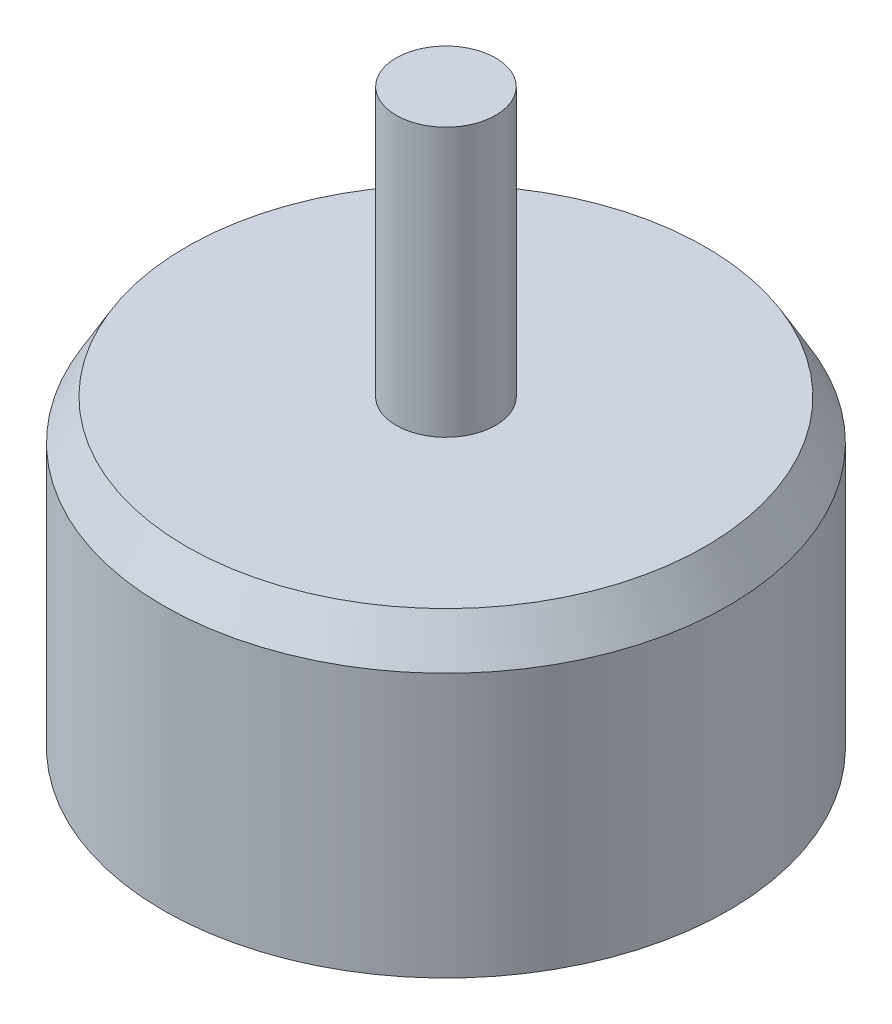
from build123d import *

# Parameters (mm, degrees)
SKETCH1_R                    = 14.2
BOSS_EXTRUDE1_DEPTH          = 17
SKETCH2_R                    = 2.5
BOSS_EXTRUDE2_DEPTH          = 13.5
CHAMFER1_SIZE                = 2
CHAMFER1_SIZE2               = 1.154700538
F_3_0_3_DIAMETER_HOLE1_D     = 3
F_3_0_3_DIAMETER_HOLE1_DEPTH = 5
F_3_0_3_DIAMETER_HOLE1_TIP   = 0.901290929
CHAMFER3_SIZE                = 3
CHAMFER3_SIZE2               = 1.732050808
SKETCH6_R                    = 5
BOSS_EXTRUDE3_DEPTH          = 2


with BuildPart() as part:
    # Sketch1 → Boss-Extrude1 (new body)
    with BuildSketch(Plane(origin=(0, 0, 0), x_dir=(1, 0, 0), z_dir=(0, 1, 0))):
        Circle(SKETCH1_R)
    extrude(amount=BOSS_EXTRUDE1_DEPTH)

    # Sketch2 → Boss-Extrude2 (add)
    with BuildSketch(Plane(origin=(0, 17, 0), x_dir=(1, 0, 0), z_dir=(0, 1, 0))):
        Circle(SKETCH2_R)
    extrude(amount=BOSS_EXTRUDE2_DEPTH)

    # Chamfer1
    chamfer1_edges = [part.edges().sort_by_distance(p)[0] for p in [
        (-14.2, 17, 0),
    ]]
    chamfer1_side = [part.faces().sort_by_distance(p)[0] for p in [
        (-14.2, 8.5, 0),
    ]]
    chamfer(chamfer1_edges, length=CHAMFER1_SIZE, length2=CHAMFER1_SIZE2, reference=chamfer1_side[0])

    # Ø3.0 (3) Diameter Hole1
    with Locations(Plane(origin=(0, 0, 0), x_dir=(-1, 0, 0), z_dir=(0, -1, 0))):
        with Locations((0, -8), (-9.5, 0), (0, 8), (9.5, 0)):
            Hole(F_3_0_3_DIAMETER_HOLE1_D / 2, depth=F_3_0_3_DIAMETER_HOLE1_DEPTH)
            with Locations((0, 0, -(F_3_0_3_DIAMETER_HOLE1_DEPTH + F_3_0_3_DIAMETER_HOLE1_TIP / 2))):  # 118° drill point
                Cone(0, F_3_0_3_DIAMETER_HOLE1_D / 2, F_3_0_3_DIAMETER_HOLE1_TIP, mode=Mode.SUBTRACT)

    # Chamfer3
    chamfer3_edges = [part.edges().sort_by_distance(p)[0] for p in [
        (-14.2, 0, 0),
    ]]
    chamfer3_side = [part.faces().sort_by_distance(p)[0] for p in [
        (0, 0, 0),
    ]]
    chamfer(chamfer3_edges, length=CHAMFER3_SIZE, length2=CHAMFER3_SIZE2, reference=chamfer3_side[0])

    # Sketch6 → Boss-Extrude3 (add)
    with BuildSketch(Plane.XZ):
        Circle(SKETCH6_R)
    extrude(amount=BOSS_EXTRUDE3_DEPTH)


solid = part.part
